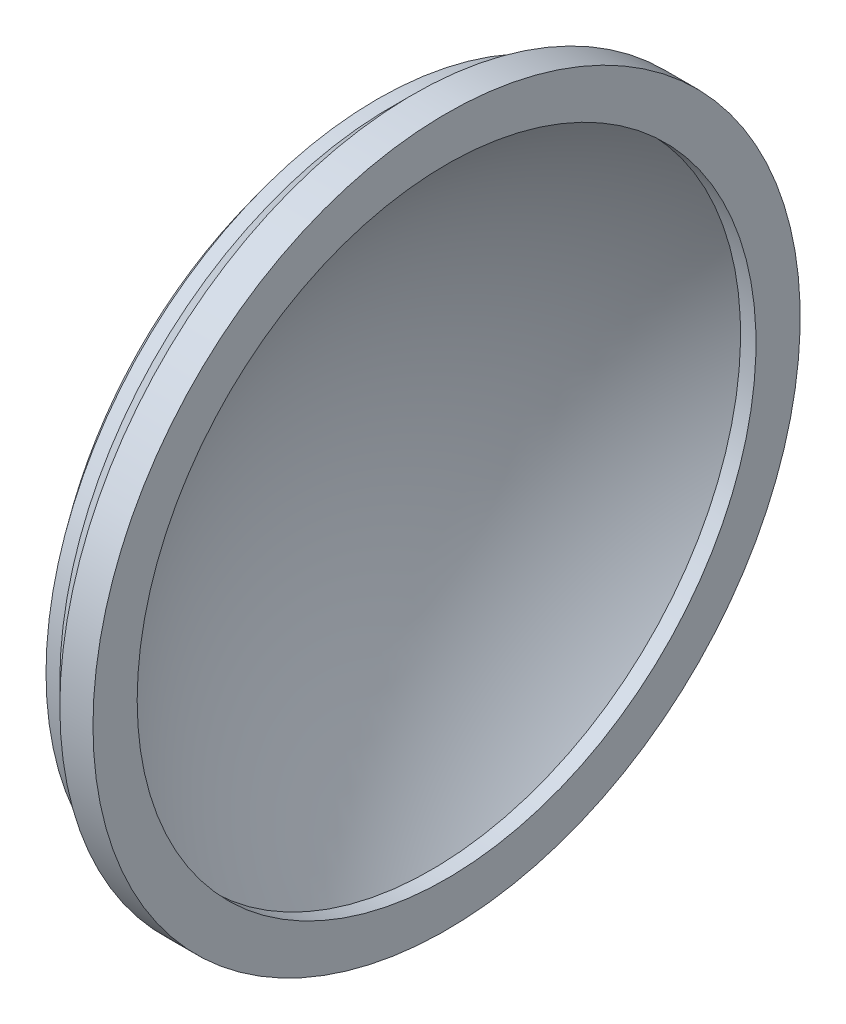
from build123d import *


with BuildPart() as part:
    # Sketch1 → Revolve1 (revolve)
    with BuildSketch(Plane.XY):
        with BuildLine():
            Line((-28.5, 60), (-26, 60))
            Line((-26, 60), (-22, 64))
            Line((-22, 64), (-16, 64))
            Line((-16, 64), (-16, 56))
            Line((-16, 56), (-18.790689802, 56))
            ThreePointArc((-18.790689802, 56), (-34.407796248, 29.913629212), (-39.845400687, 0))
            Line((-39.845400687, 0), (-49.845400687, 0))
            ThreePointArc((-49.845400687, 0), (-44.350112671, 31.841899011), (-28.5, 60))
        make_face()
    revolve(axis=Axis((-162.413763562, 0, 0), (1, 0, 0)))


solid = part.part
